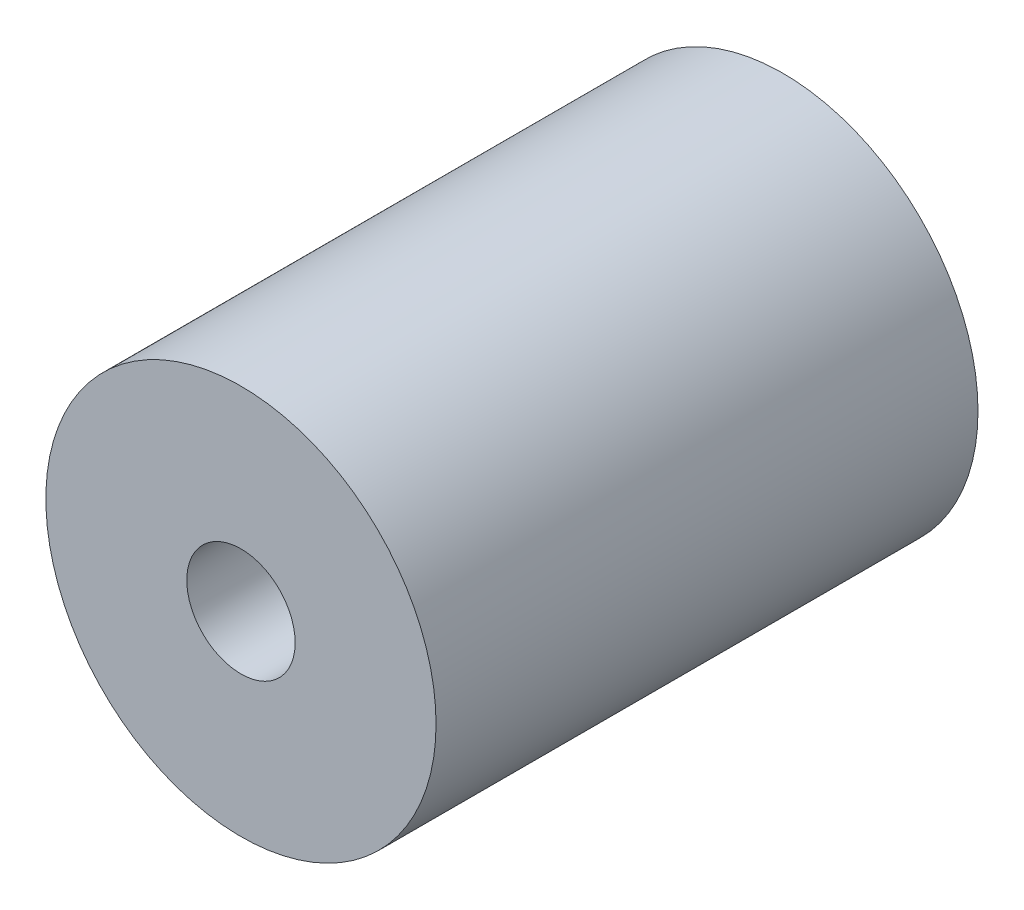
from build123d import *

# Parameters (mm, degrees)
SKETCH1_R           = 9
BOSS_EXTRUDE1_DEPTH = 12.5
SKETCH2_R           = 2.5
CUT_EXTRUDE1_DEPTH  = 26
SKETCH3_R           = 4
CUT_EXTRUDE2_DEPTH  = 17.5


with BuildPart() as part:
    # Sketch1 → Boss-Extrude1 (new body, symmetric)
    with BuildSketch(Plane.XY):
        Circle(SKETCH1_R)
    extrude(amount=BOSS_EXTRUDE1_DEPTH, both=True)

    # Sketch2 → Cut-Extrude1 (cut, through all)
    with BuildSketch(Plane.XY.offset(12.5)):
        Circle(SKETCH2_R)
    extrude(amount=-CUT_EXTRUDE1_DEPTH, mode=Mode.SUBTRACT)

    # Sketch3 → Cut-Extrude2 (cut)
    with BuildSketch(Plane(origin=(0, 0, -12.5), x_dir=(-1, 0, 0), z_dir=(0, 0, -1))):
        Circle(SKETCH3_R)
    extrude(amount=-CUT_EXTRUDE2_DEPTH, mode=Mode.SUBTRACT)


solid = part.part
